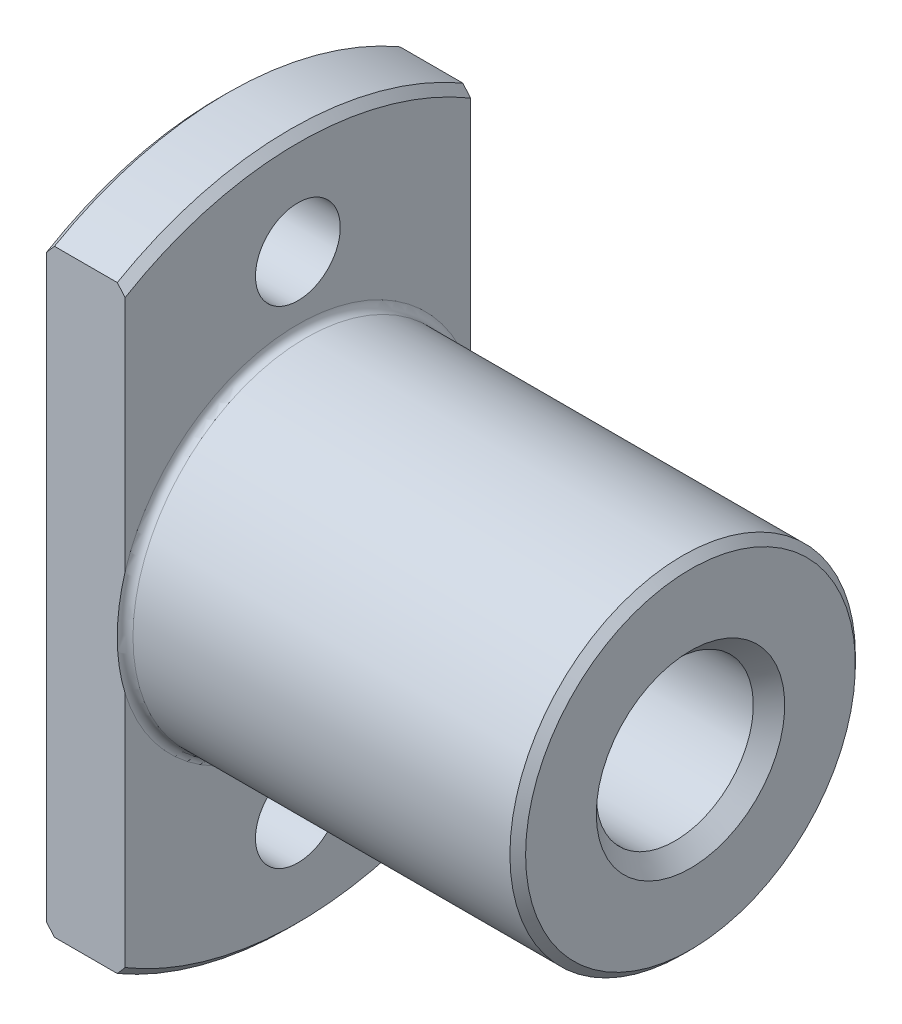
from build123d import *

# Parameters (mm, degrees)
SKETCH3_W          = 5
SKETCH3_H          = 2.7
SKETCH4_W          = 5
SKETCH4_H          = 2.7
SKETCH5_W          = 5
SKETCH5_H          = 2.7
SKETCH6_W          = 5
SKETCH6_H          = 2.7
CUT_EXTRUDE1_DEPTH = 5


with BuildPart() as part:
    # Sketch1 → Revolve1 (revolve)
    with BuildSketch(Plane.XY):
        with BuildLine():
            Line((0, 0), (0, 21.5))
            Line((0, 21.5), (0.5, 22))
            Line((0.5, 22), (4.5, 22))
            Line((4.5, 22), (5, 21.5))
            Line((5, 21.5), (5, 11.5))
            ThreePointArc((5, 11.5), (5.146446609, 11.146446609), (5.5, 11))
            Line((5.5, 11), (29.5, 11))
            Line((29.5, 11), (30, 10.5))
            Line((30, 10.5), (30, 0))
            Line((30, 0), (0, 0))
        make_face()
    revolve(axis=Axis((30, 0, 0), (-1, 0, 0)))

    # Sketch2 → Cut-Revolve1 (revolve, cut)
    with BuildSketch(Plane.XY):
        Polygon((0, 0), (0, 6), (1, 5), (29, 5), (30, 6), (30, 0), align=None)
    revolve(axis=Axis((30, 0, 0), (-1, 0, 0)), mode=Mode.SUBTRACT)

    # Sketch3 → Cut-Revolve2 (revolve, cut)
    with BuildSketch(Plane.XY):
        with Locations((2.5, 16.85)):
            Rectangle(SKETCH3_W, SKETCH3_H)
    revolve(axis=Axis((5, 15.5, 0), (-1, 0, 0)), mode=Mode.SUBTRACT)

    # Sketch4 → Cut-Revolve3 (revolve, cut)
    with BuildSketch(Plane.XY.offset(15.5)):
        with Locations((2.5, 1.35)):
            Rectangle(SKETCH4_W, SKETCH4_H)
    revolve(axis=Axis((5, 0, 15.5), (-1, 0, 0)), mode=Mode.SUBTRACT)

    # Sketch5 → Cut-Revolve4 (revolve, cut)
    with BuildSketch(Plane.XY):
        with Locations((2.5, -14.15)):
            Rectangle(SKETCH5_W, SKETCH5_H)
    revolve(axis=Axis((5, -15.5, 0), (-1, 0, 0)), mode=Mode.SUBTRACT)

    # Sketch6 → Cut-Revolve5 (revolve, cut)
    with BuildSketch(Plane.XY.offset(-15.5)):
        with Locations((2.5, 1.35)):
            Rectangle(SKETCH6_W, SKETCH6_H)
    revolve(axis=Axis((5, 0, -15.5), (-1, 0, 0)), mode=Mode.SUBTRACT)

    # Sketch7 → Cut-Extrude1 (cut)
    with BuildSketch(Plane.ZY):
        with BuildLine():
            Line((11, 19.052558883), (11, -19.052558883))
            ThreePointArc((11, -19.052558883), (22, 0), (11, 19.052558883))
        make_face()
        with BuildLine():
            Line((-11, 19.052558883), (-11, -19.052558883))
            ThreePointArc((-11, -19.052558883), (-22, 0), (-11, 19.052558883))
        make_face()
    extrude(amount=-CUT_EXTRUDE1_DEPTH, mode=Mode.SUBTRACT)


solid = part.part
